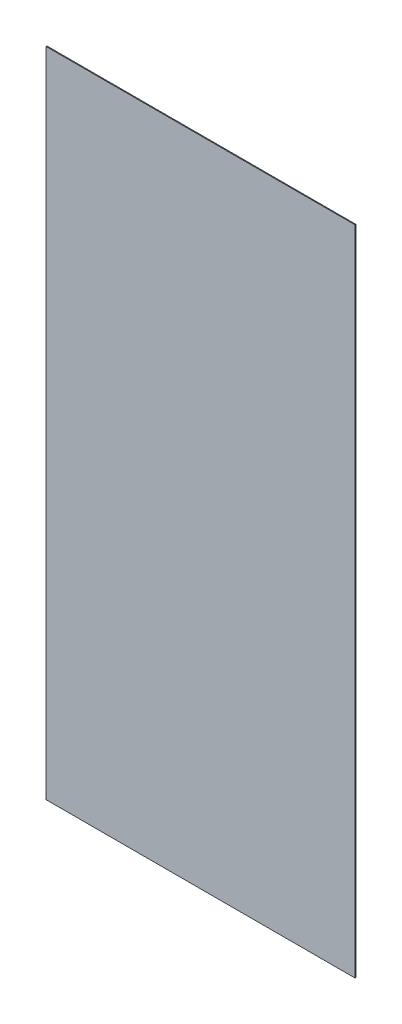
from build123d import *

# Parameters (mm, degrees)
SKETCH1_W           = 1420
SKETCH1_H           = 3000
BOSS_EXTRUDE4_DEPTH = 4


with BuildPart() as part:
    # Sketch1 → Boss-Extrude4 (new body)
    with BuildSketch(Plane.XY):
        with Locations((-710, -1500)):
            Rectangle(SKETCH1_W, SKETCH1_H)
    extrude(amount=BOSS_EXTRUDE4_DEPTH)


solid = part.part
